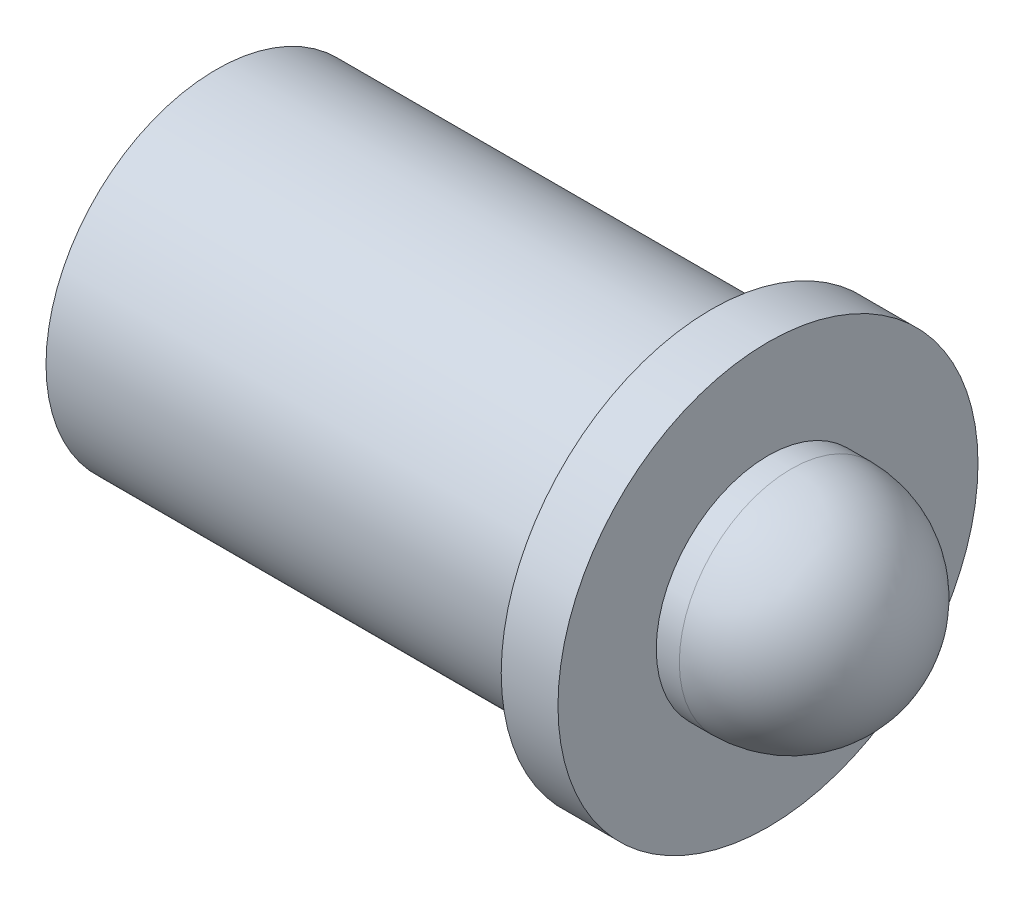
from build123d import *


with BuildPart() as part:
    # Sketch1 → Revolve1 (revolve)
    with BuildSketch(Plane.XY):
        Polygon((12.3444, 4.699), (11.0744, 4.699), (11.0744, 3.81), (0, 3.81), (0, 3.302), (10.16, 3.302), (10.16, 2.5), (12.3444, 2.5), align=None)
    revolve(axis=Axis((0, 0, 0), (1, 0, 0)))

    # Sketch7 → Revolve4 (revolve)
    with BuildSketch(Plane.XY):
        with BuildLine():
            Line((10.16, 3.302), (9.2837, 3.302))
            Line((9.2837, 3.302), (9.2837, 0))
            Line((9.2837, 0), (12.86069262, 0))
            Line((12.86069262, 0), (15.36069262, 0))
            ThreePointArc((15.36069262, 0), (14.628459573, 1.767766953), (12.86069262, 2.5))
            Line((12.86069262, 2.5), (10.16, 2.5))
            Line((10.16, 2.5), (10.16, 3.302))
        make_face()
    revolve(axis=Axis((12.86069262, 0, 0), (1, 0, 0)))


solid = part.part
